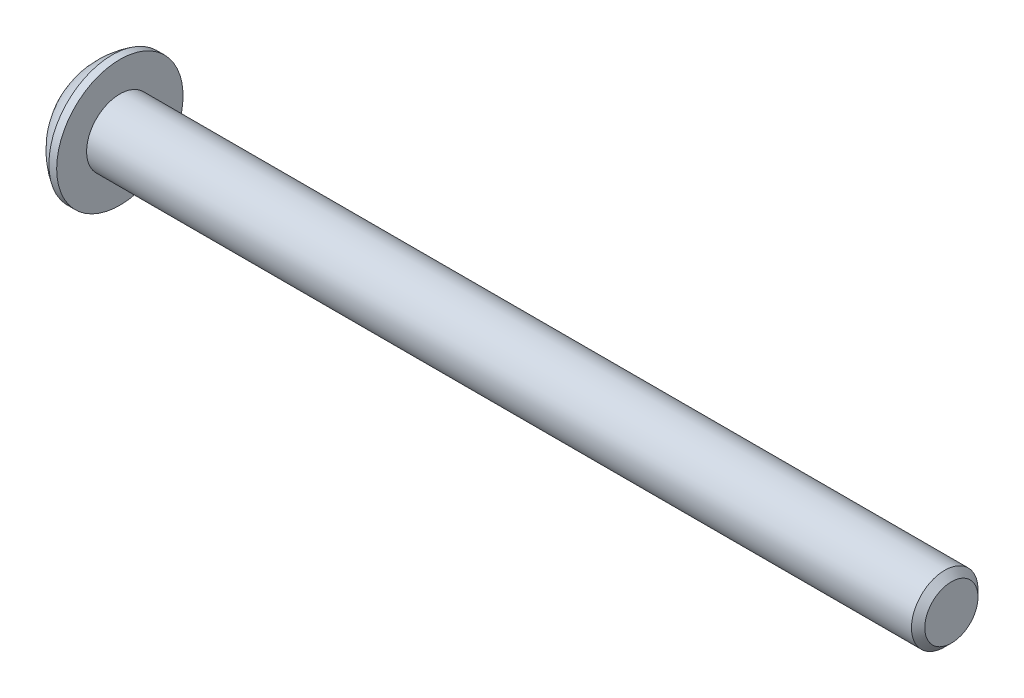
from build123d import *

# Parameters (mm, degrees)
CHAMFER1_SIZE      = 0.3
CUT_EXTRUDE1_DEPTH = 1


with BuildPart() as part:
    # Sketch2 → Revolve1 (revolve)
    with BuildSketch(Plane.XY):
        with BuildLine():
            Line((0, 0), (39.15, 0))
            Line((39.15, 0), (39.15, 1.5))
            Line((39.15, 1.5), (1.65, 1.5))
            Line((1.65, 1.5), (1.65, 2.85))
            Line((1.65, 2.85), (1.3, 2.85))
            ThreePointArc((1.3, 2.85), (0.549895392, 2.228823502), (0, 1.425))
            Line((0, 1.425), (0, 0))
        make_face()
    revolve(axis=Axis((0, 0, 0), (1, 0, 0)))

    # Chamfer1
    chamfer1_edges = [part.edges().sort_by_distance(p)[0] for p in [
        (39.15, -1.5, 0),
    ]]
    chamfer(chamfer1_edges, length=CHAMFER1_SIZE)

    # Sketch3 → Cut-Extrude1 (cut)
    with BuildSketch(Plane.ZY):
        Polygon((0.576043408, 1.000753379), (-0.578656145, 0.999244915), (-1.154699553, -0.001508464), (-0.576043408, -1.000753379), (0.578656145, -0.999244915), (1.154699553, 0.001508464), align=None)
    extrude(amount=-CUT_EXTRUDE1_DEPTH, mode=Mode.SUBTRACT)


solid = part.part
